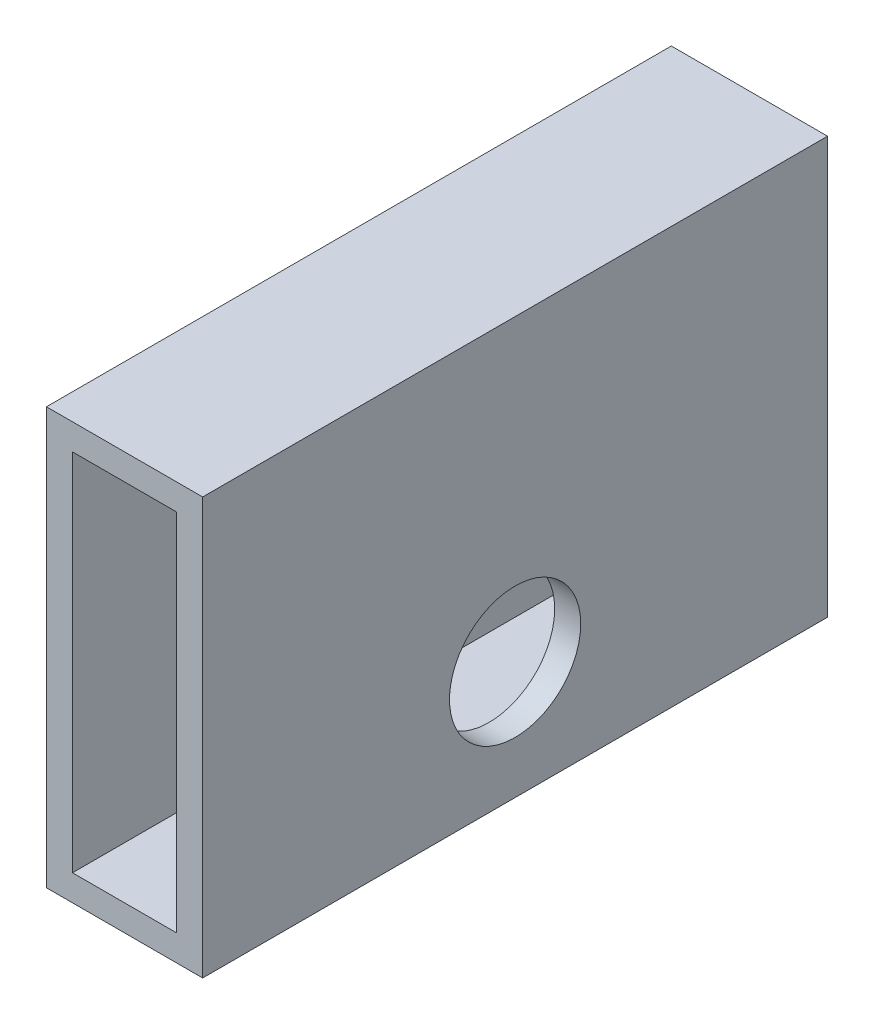
from build123d import *

# Parameters (mm, degrees)
SKETCH1_W           = 19.05
SKETCH1_H           = 50.8
BOSS_EXTRUDE1_DEPTH = 76.2
CUT_EXTRUDE1_REACH  = 78.2
SKETCH2_W           = 12.7
SKETCH2_H           = 44.45
SKETCH4_R           = 8.001
CUT_EXTRUDE2_DEPTH  = 20.05


with BuildPart() as part:
    # Sketch1 → Boss-Extrude1 (new body)
    with BuildSketch(Plane.XY):
        Rectangle(SKETCH1_W, SKETCH1_H)
    extrude(amount=-BOSS_EXTRUDE1_DEPTH)

    # Sketch2 → Cut-Extrude1 (cut, up to next)
    with BuildSketch(Plane.XY, mode=Mode.PRIVATE) as cut_extrude1_sk1:
        Rectangle(SKETCH2_W, SKETCH2_H)
    cut_extrude1_tool1 = extrude(cut_extrude1_sk1.sketch, amount=-CUT_EXTRUDE1_REACH, mode=Mode.PRIVATE) & part.part
    add(cut_extrude1_tool1.solids().sort_by_distance((0, 0, 0))[0], mode=Mode.SUBTRACT)

    # Sketch4 → Cut-Extrude2 (cut, through all)
    with BuildSketch(Plane(origin=(9.525, 0, 0), x_dir=(0, 0, -1), z_dir=(1, 0, 0))):
        with Locations((38.1, -11.049)):
            Circle(SKETCH4_R)
    extrude(amount=-CUT_EXTRUDE2_DEPTH, mode=Mode.SUBTRACT)


solid = part.part
